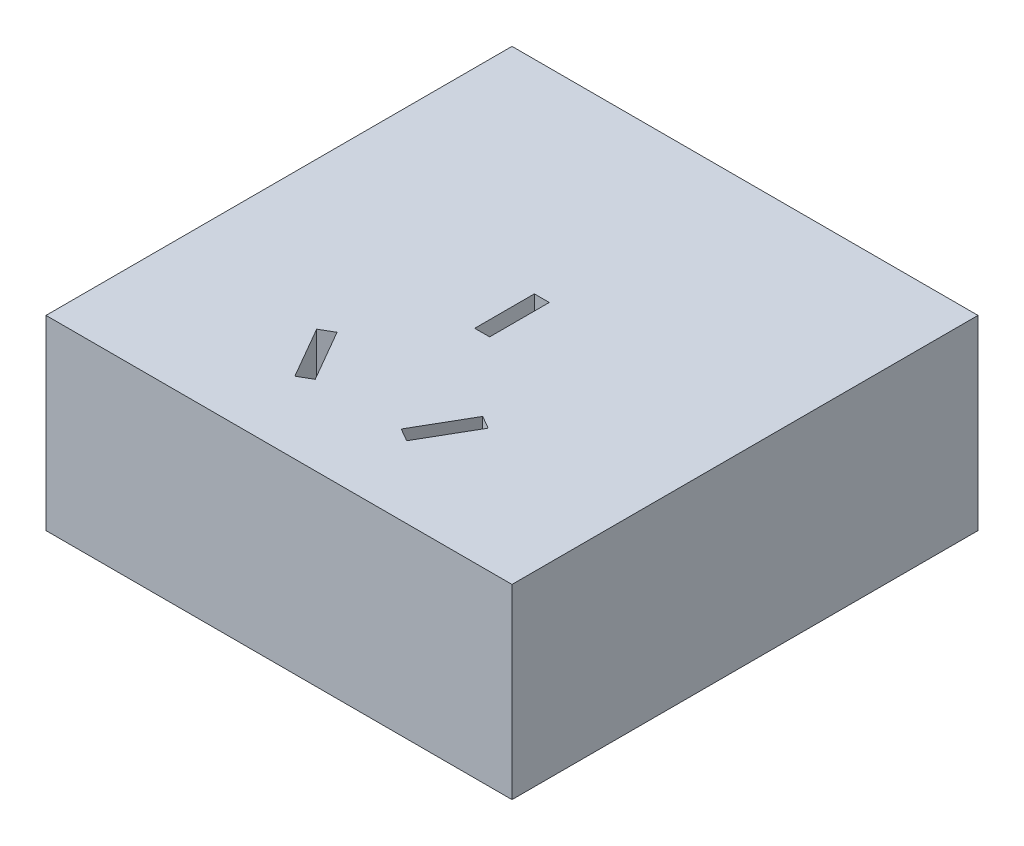
from build123d import *

# Parameters (mm, degrees)
SKETCH_1_W          = 50
SKETCH_1_H          = 50
EXTRUDE_1_DEPTH     = 20
CUT_EXTRUDE_1_DEPTH = 20


with BuildPart() as part:
    # Эскиз1 → Бобышка-Вытянуть1 (new body)
    with BuildSketch(Plane(origin=(0, 0, 0), x_dir=(1, 0, 0), z_dir=(0, 1, 0))):
        Rectangle(SKETCH_1_W, SKETCH_1_H)
    extrude(amount=EXTRUDE_1_DEPTH)

    # Эскиз2 → Вырез-Вытянуть1 (cut)
    with BuildSketch(Plane(origin=(0, 20, 0), x_dir=(1, 0, 0), z_dir=(0, 1, 0))):
        Polygon((-0.8, 3.2), (0.8, 3.2), (0.8, -3.2), (0, -3.2), (-0.8, -3.2), align=None)
        Polygon((4.614359354, -16.5), (7.814359354, -10.957437416), (9.2, -11.757437416), (6, -17.3), align=None)
        Polygon((-6, -17.3), (-4.614359354, -16.5), (-7.814359354, -10.957437416), (-9.2, -11.757437416), align=None)
    extrude(amount=-CUT_EXTRUDE_1_DEPTH, mode=Mode.SUBTRACT)


solid = part.part
